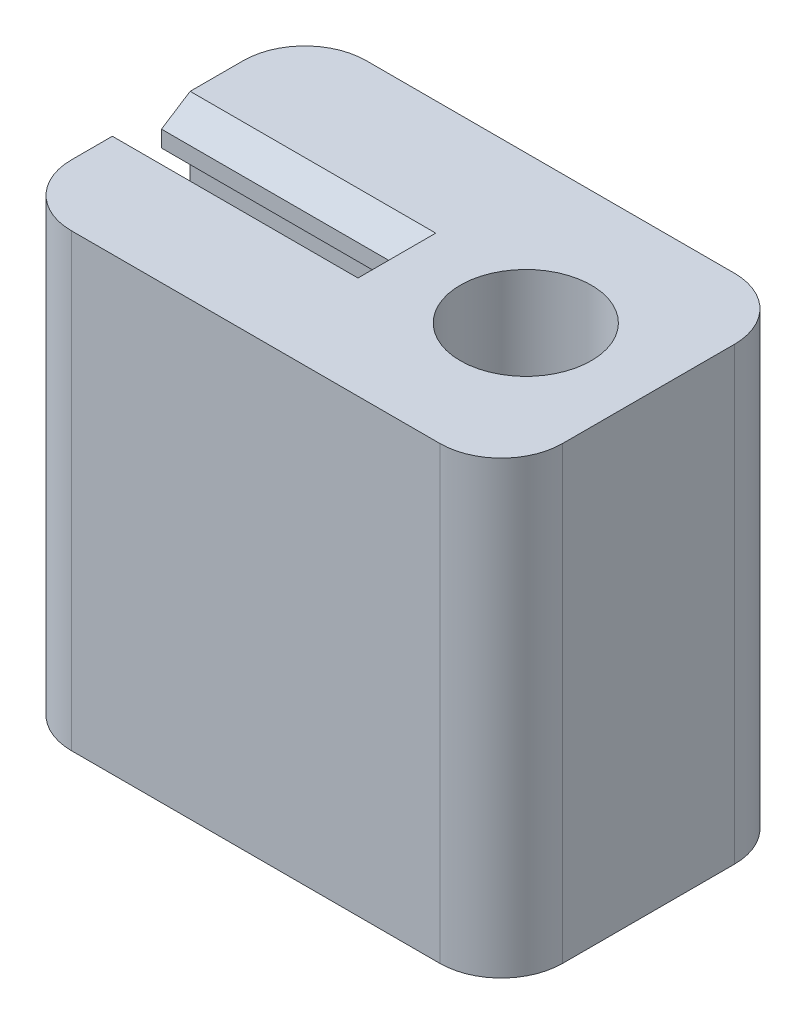
from build123d import *

# Parameters (mm, degrees)
SKETCH1_R           = 1.6
BOSS_EXTRUDE1_DEPTH = 11
CUT_EXTRUDE1_DEPTH  = 6


with BuildPart() as part:
    # Sketch1 → Boss-Extrude1 (new body)
    with BuildSketch(Plane(origin=(0, 0, 0), x_dir=(1, 0, 0), z_dir=(0, 1, 0))):
        with BuildLine():
            Line((-4.5, -3.6), (4.5, -3.6))
            ThreePointArc((4.5, -3.6), (5.560660172, -3.160660172), (6, -2.1))
            Line((6, -2.1), (6, 2.1))
            ThreePointArc((6, 2.1), (5.560660172, 3.160660172), (4.5, 3.6))
            Line((4.5, 3.6), (-4.5, 3.6))
            ThreePointArc((-4.5, 3.6), (-5.560660172, 3.160660172), (-6, 2.1))
            Line((-6, 2.1), (-6, -2.1))
            ThreePointArc((-6, -2.1), (-5.560660172, -3.160660172), (-4.5, -3.6))
        make_face()
        with Locations((3, 0)):
            Circle(SKETCH1_R, mode=Mode.SUBTRACT)
    extrude(amount=-BOSS_EXTRUDE1_DEPTH)

    # Sketch2 → Cut-Extrude1 (cut)
    with BuildSketch(Plane.ZY.offset(6)):
        Polygon((-0.333384704, -11), (1.1, -11), (1.1, 0), (-0.8, 0), (-0.1, -0.45), (-0.1, -0.85), (-0.8, -1.3), (-0.8, -1.65), (-0.8, -1.999993395), (-0.1, -2.449993395), (-0.1, -2.849993395), (-0.8, -3.299993395), (-0.8, -3.64998679), (-0.8, -3.99998679), (-0.1, -4.44998679), (-0.1, -4.84998679), (-0.8, -5.29998679), (-0.8, -5.649980186), (-0.8, -5.999980186), (-0.1, -6.449980186), (-0.1, -6.849980186), (-0.8, -7.299980186), (-0.8, -7.649973581), (-0.8, -7.999973581), (-0.1, -8.449973581), (-0.1, -8.849973581), (-0.8, -9.299973581), (-0.8, -9.649966976), (-0.8, -9.999966976), (-0.1, -10.449966976), (-0.1, -10.849966976), align=None)
    extrude(amount=-CUT_EXTRUDE1_DEPTH, mode=Mode.SUBTRACT)


solid = part.part
